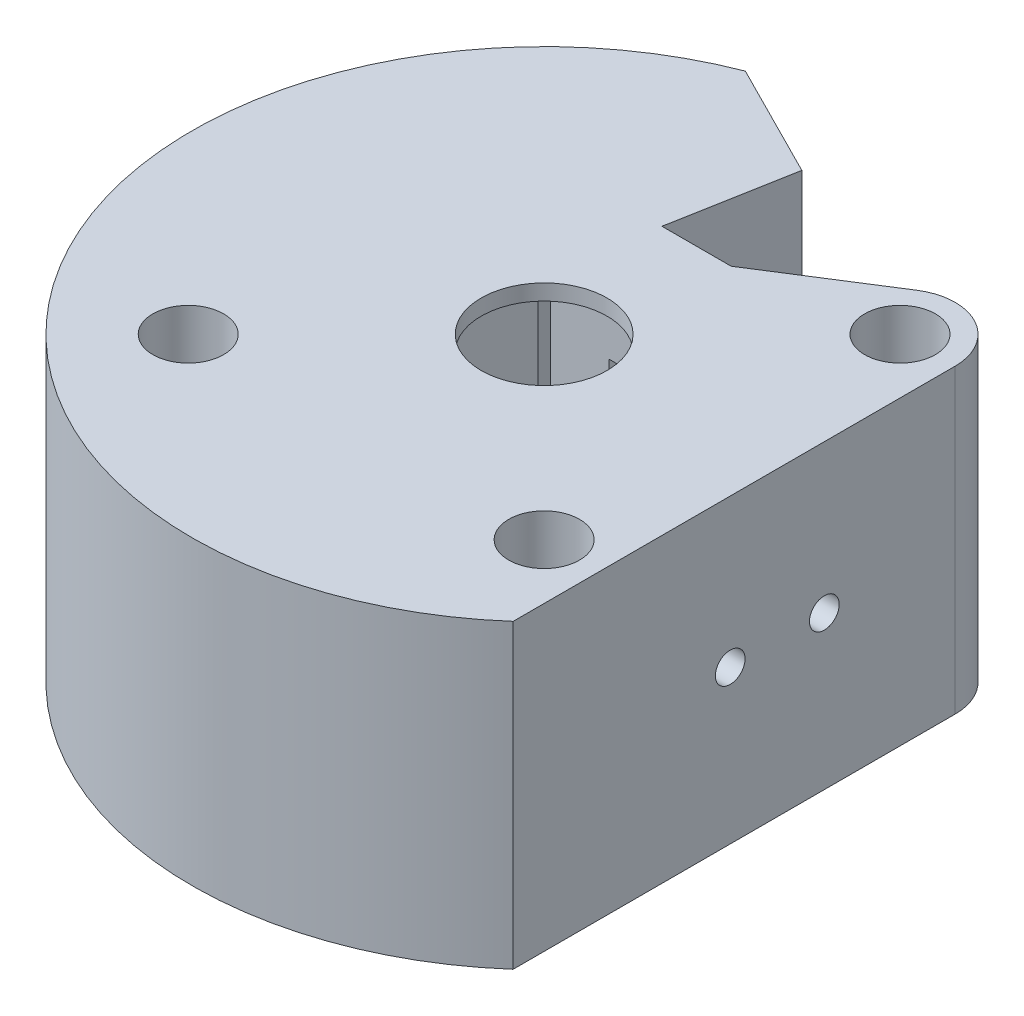
from build123d import *
from build123d.topology import SkipClean

# Parameters (mm, degrees)
SKETCH2_R           = 3.571875
BOSS_EXTRUDE1_DEPTH = 1.905
SKETCH3_R           = 3.571875
BOSS_EXTRUDE2_DEPTH = 19.558
SKETCH4_R           = 3.571875
BOSS_EXTRUDE3_DEPTH = 7.366
SKETCH5_R           = 3.571875
BOSS_EXTRUDE4_DEPTH = 1.5875
SKETCH6_R           = 1.5
CUT_EXTRUDE3_DEPTH  = 4


with BuildPart() as part:
    # Sketch2 → Boss-Extrude1 (new body)
    with BuildSketch(Plane(origin=(0, 0, 0), x_dir=(1, 0, 0), z_dir=(0, 1, 0))):
        with BuildLine():
            Line((10.05, -30.05), (-10.05, -30.05))
            Line((-10.05, -30.05), (-10.05, 10.05))
            Line((-10.05, 10.05), (-3.4925, 10.05))
            Line((-3.4925, 10.05), (-3.4925, 15.384))
            Line((-3.4925, 15.384), (-1.318232079, 27.330889022))
            Line((-1.318232079, 27.330889022), (-10.839769253, 32.141975578))
            Line((-10.839769253, 32.141975578), (-12.849275114, 33.15734804))
            ThreePointArc((-12.849275114, 33.15734804), (-30.38177824, -18.478667457), (23.532387242, -26.659714002))
            Line((23.532387242, -26.659714002), (23.532387242, -17.960512242))
            Line((23.532387242, -17.960512242), (23.532387242, 17.960512242))
            ThreePointArc((23.532387242, 17.960512242), (20.645690581, 22.842684741), (14.976700581, 22.666110928))
            Line((14.976700581, 22.666110928), (3.4925, 15.384))
            Line((3.4925, 15.384), (3.4925, 10.05))
            Line((3.4925, 10.05), (10.05, 10.05))
            Line((10.05, 10.05), (10.05, -30.05))
        make_face()
        with Locations(Location((17.960512242, 17.960512242, 0), (0, 0, 90))):
            Circle(SKETCH2_R, mode=Mode.SUBTRACT)
        with Locations(Location((17.960512242, -17.960512242, 0), (0, 0, 90))):
            Circle(SKETCH2_R, mode=Mode.SUBTRACT)
        with Locations(Location((-17.960512242, -17.960512242, 0), (0, 0, 90))):
            Circle(SKETCH2_R, mode=Mode.SUBTRACT)
    extrude(amount=BOSS_EXTRUDE1_DEPTH)

    # Sketch3 → Boss-Extrude2 (add)
    # profile 1 of 2: a face of its own
    with SkipClean():  # the faces are left unmerged after this step: merging them gives an invalid solid
        with BuildSketch(Plane(origin=(0, 1.905, 0), x_dir=(1, 0, 0), z_dir=(0, 1, 0))):
            with BuildLine():
                Line((-10.839769253, 32.141975578), (-32.833307795, -11.385051501))
                Line((-32.833307795, -11.385051501), (-23.311770621, -16.196138057))
                Line((-23.311770621, -16.196138057), (-10.3363742, 9.483241835))
                ThreePointArc((-10.3363742, 9.483241835), (-10.197196408, 9.432296011), (-10.05, 9.415))
                Line((-10.05, 9.415), (-10.05, -30.05))
                Line((-10.05, -30.05), (10.05, -30.05))
                Line((10.05, -30.05), (10.05, 10.05))
                Line((10.05, 10.05), (3.4925, 10.05))
                Line((3.4925, 10.05), (3.4925, 15.384))
                Line((3.4925, 15.384), (14.976700581, 22.666110928))
                ThreePointArc((14.976700581, 22.666110928), (20.645690581, 22.842684741), (23.532387242, 17.960512242))
                Line((23.532387242, 17.960512242), (23.532387242, -26.659714002))
                ThreePointArc((23.532387242, -26.659714002), (-30.38177824, -18.478667457), (-12.849275114, 33.15734804))
                Line((-12.849275114, 33.15734804), (-10.839769253, 32.141975578))
            make_face()
            with Locations(Location((17.960512242, 17.960512242, 0), (0, 0, 90))):
                Circle(SKETCH3_R, mode=Mode.SUBTRACT)
            with Locations(Location((17.960512242, -17.960512242, 0), (0, 0, 90))):
                Circle(SKETCH3_R, mode=Mode.SUBTRACT)
            with Locations(Location((-17.960512242, -17.960512242, 0), (0, 0, 90))):
                Circle(SKETCH3_R, mode=Mode.SUBTRACT)
        # profile 2 of 2: a face of its own
        with BuildSketch(Plane(origin=(0, 1.905, 0), x_dir=(1, 0, 0), z_dir=(0, 1, 0))):
            with BuildLine():
                Line((-1.318232079, 27.330889022), (-9.7636258, 10.616758165))
                ThreePointArc((-9.7636258, 10.616758165), (-9.509133743, 10.382699101), (-9.415, 10.05))
                Line((-9.415, 10.05), (-3.4925, 10.05))
                Line((-3.4925, 10.05), (-3.4925, 15.384))
                Line((-3.4925, 15.384), (-1.318232079, 27.330889022))
            make_face()
        extrude(amount=BOSS_EXTRUDE2_DEPTH)

    # Sketch4 → Boss-Extrude3 (add)
    with SkipClean():  # the faces are left unmerged after this step: merging them gives an invalid solid
        with BuildSketch(Plane(origin=(0, 21.463, 0), x_dir=(1, 0, 0), z_dir=(0, 1, 0))):
            with BuildLine():
                Line((0, 10.05), (-3.4925, 10.05))
                Line((-3.4925, 10.05), (-9.415, 10.05))
                ThreePointArc((-9.415, 10.05), (-9.509133743, 10.382699101), (-9.7636258, 10.616758165))
                Line((-9.7636258, 10.616758165), (-1.318232079, 27.330889022))
                Line((-1.318232079, 27.330889022), (-3.4925, 15.384))
                Line((-3.4925, 15.384), (3.4925, 15.384))
                Line((3.4925, 15.384), (14.976700581, 22.666110928))
                ThreePointArc((14.976700581, 22.666110928), (20.645690581, 22.842684741), (23.532387242, 17.960512242))
                Line((23.532387242, 17.960512242), (23.532387242, -26.659714002))
                ThreePointArc((23.532387242, -26.659714002), (-30.38177824, -18.478667457), (-12.849275114, 33.15734804))
                Line((-12.849275114, 33.15734804), (-10.839769253, 32.141975578))
                Line((-10.839769253, 32.141975578), (-32.833307795, -11.385051501))
                Line((-32.833307795, -11.385051501), (-23.311770621, -16.196138057))
                Line((-23.311770621, -16.196138057), (-10.3363742, 9.483241835))
                ThreePointArc((-10.3363742, 9.483241835), (-10.197196408, 9.432296011), (-10.05, 9.415))
                Line((-10.05, 9.415), (-10.05, -30.05))
                Line((-10.05, -30.05), (10.05, -30.05))
                Line((10.05, -30.05), (10.05, 10.05))
                Line((10.05, 10.05), (3.4925, 10.05))
                Line((3.4925, 10.05), (0, 10.05))
            make_face()
            with Locations(Location((17.960512242, 17.960512242, 0), (0, 0, 90))):
                Circle(SKETCH4_R, mode=Mode.SUBTRACT)
            with Locations(Location((17.960512242, -17.960512242, 0), (0, 0, 90))):
                Circle(SKETCH4_R, mode=Mode.SUBTRACT)
            with Locations(Location((-17.960512242, -17.960512242, 0), (0, 0, 90))):
                Circle(SKETCH4_R, mode=Mode.SUBTRACT)
        extrude(amount=BOSS_EXTRUDE3_DEPTH)

    # Sketch5 → Boss-Extrude4 (add)
    with SkipClean():  # the faces are left unmerged after this step: merging them gives an invalid solid
        with BuildSketch(Plane(origin=(0, 28.829, 0), x_dir=(1, 0, 0), z_dir=(0, 1, 0))):
            with BuildLine():
                Line((3.4925, 15.384), (-3.4925, 15.384))
                Line((-3.4925, 15.384), (-1.318232079, 27.330889022))
                Line((-1.318232079, 27.330889022), (-12.849275114, 33.15734804))
                ThreePointArc((-12.849275114, 33.15734804), (-30.38177824, -18.478667457), (23.532387242, -26.659714002))
                Line((23.532387242, -26.659714002), (23.532387242, 17.960512242))
                ThreePointArc((23.532387242, 17.960512242), (20.645690581, 22.842684741), (14.976700581, 22.666110928))
                Line((14.976700581, 22.666110928), (3.4925, 15.384))
            make_face()
            with Locations(Location((17.960512242, 17.960512242, 0), (0, 0, 90))):
                Circle(SKETCH5_R, mode=Mode.SUBTRACT)
            with Locations(Location((17.960512242, -17.960512242, 0), (0, 0, 90))):
                Circle(SKETCH5_R, mode=Mode.SUBTRACT)
            with Locations(Location((-17.960512242, -17.960512242, 0), (0, 0, 90))):
                Circle(SKETCH5_R, mode=Mode.SUBTRACT)
            with BuildLine():
                ThreePointArc((4.490128061, 4.490128061), (0, 6.35), (-4.490128061, 4.490128061))
                ThreePointArc((-4.490128061, 4.490128061), (0, -6.35), (4.490128061, 4.490128061))
            make_face(mode=Mode.SUBTRACT)
        extrude(amount=BOSS_EXTRUDE4_DEPTH)

    # Sketch6 → Cut-Extrude3 (cut)
    with SkipClean():  # the faces are left unmerged after this step: merging them gives an invalid solid
        with BuildSketch(Plane(origin=(23.532387242, 0, 0), x_dir=(0, 0, -1), z_dir=(1, 0, 0))):
            with Locations((-4.75, 15.449)):
                Circle(SKETCH6_R)
            with Locations((4.75, 15.449)):
                Circle(SKETCH6_R)
        extrude(amount=-CUT_EXTRUDE3_DEPTH, mode=Mode.SUBTRACT)


solid = part.part
